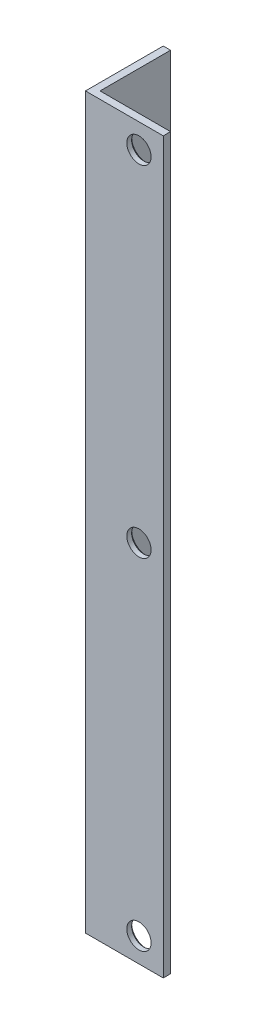
from build123d import *

# Parameters (mm, degrees)
EXTRUDE_1_DEPTH     = 300
SKETCH_2_R          = 5
CUT_EXTRUDE_1_DEPTH = 33
CHAMFER_1_SIZE      = 1


with BuildPart() as part:
    # Эскиз1 → Вытянуть-Тонкостенный1 (new body)
    with BuildSketch(Plane(origin=(0, 0, 0), x_dir=(1, 0, 0), z_dir=(0, 1, 0))):
        Polygon((0, 32), (0, 0), (32, 0), (32, 3), (3, 3), (3, 32), align=None)
    extrude(amount=EXTRUDE_1_DEPTH)

    # Эскиз2 → Вырез-Вытянуть1 (cut, through all)
    with BuildSketch(Plane.XY):
        with Locations((22, 10)):
            Circle(SKETCH_2_R)
        with Locations((22, 150)):
            Circle(SKETCH_2_R)
        with Locations((22, 290)):
            Circle(SKETCH_2_R)
    extrude(amount=-CUT_EXTRUDE_1_DEPTH, mode=Mode.SUBTRACT)

    # Фаска1
    chamfer_1_edges = [part.edges().sort_by_distance(p)[0] for p in [
        (17, 10, -3),
        (17, 150, -3),
        (17, 290, -3),
    ]]
    chamfer(chamfer_1_edges, length=CHAMFER_1_SIZE)


solid = part.part
